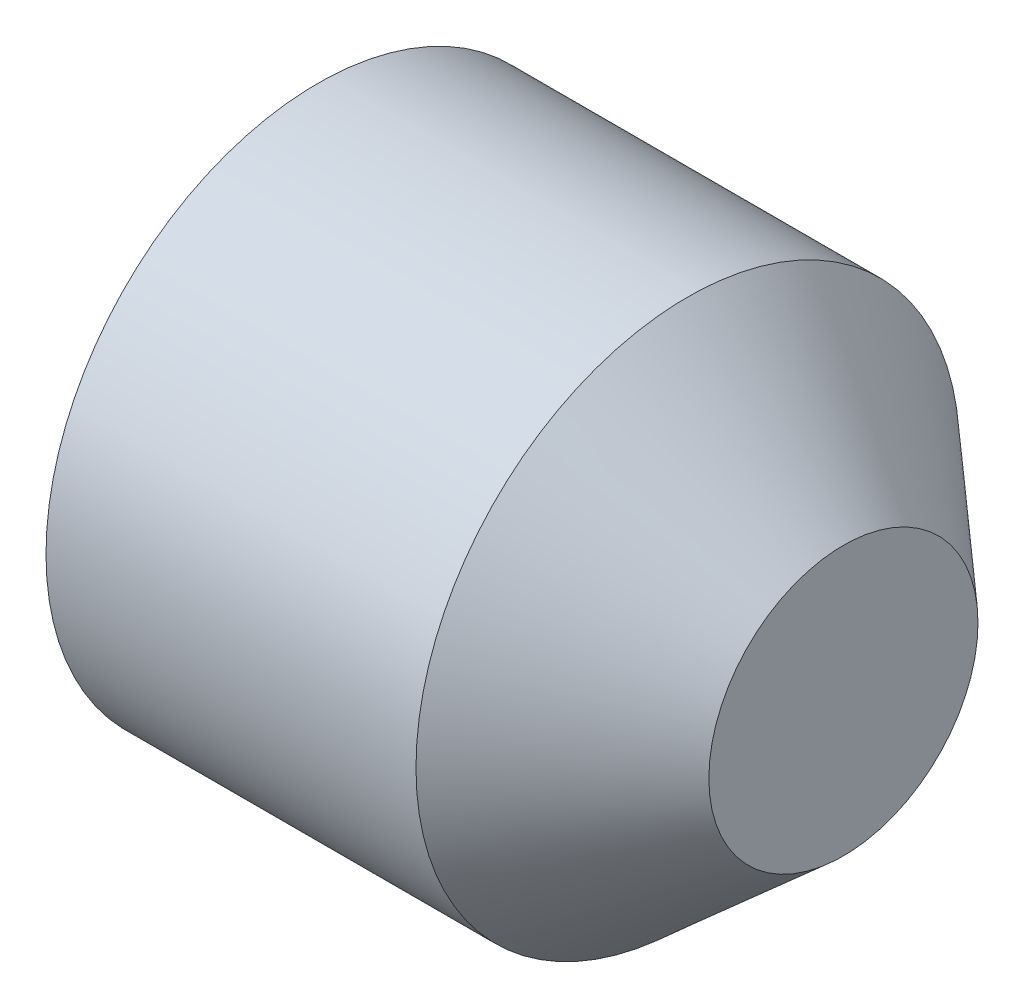
from build123d import *

# Parameters (mm, degrees)
SKETCH9_R           = 1.61
BOSS_EXTRUDE1_DEPTH = 3
CIRPATTERN5_COUNT   = 12
CIRPATTERN6_COUNT   = 12


with BuildPart() as part:
    # Sketch1 → Revolve1 (revolve)
    with BuildSketch(Plane.XY):
        Polygon((0, 50), (67, 50), (67, 150), (271.13431362, 150), (356.984864911, 74.249513566), (356.984864911, 0), (0, 0), align=None)
    revolve(axis=Axis((0, 0, 0), (1, 0, 0)))

    # Sketch3 → Cut-Loft1 section 0
    with BuildSketch(Plane.ZY):
        with BuildLine():
            Line((-1, 24.842486485), (-2.446479865, 52.442966509))
            ThreePointArc((-2.446479865, 52.442966509), (0, 52.5), (2.446479865, 52.442966509))
            Line((2.446479865, 52.442966509), (1, 24.842486485))
            Line((1, 24.842486485), (-1, 24.842486485))
        make_face()
    # Sketch12 → Cut-Loft1 section 1
    with BuildSketch(Plane.ZY.offset(-25)):
        with BuildLine():
            Line((-22.339750272, 46.956741345), (-10.661657412, 22.47311051))
            Line((-10.661657412, 22.47311051), (-8.351958581, 23.429819091))
            Line((-8.351958581, 23.429819091), (-17.40684132, 49.000019135))
            ThreePointArc((-17.40684132, 49.000019135), (-19.899538483, 48.041735691), (-22.339750272, 46.956741345))
        make_face()
    cut_loft1 = loft(mode=Mode.SUBTRACT)

    # CirPattern6: Cut-Loft1 ×12 about axis
    cirpattern6_axis = Axis((0, 0, 0), (1, 0, 0))
    for i in range(1, CIRPATTERN6_COUNT):
        add(cut_loft1.rotate(cirpattern6_axis, i * 360 / CIRPATTERN6_COUNT), mode=Mode.SUBTRACT)


with BuildPart() as body_2:
    # Sketch9 → Boss-Extrude1 (new body)
    with BuildSketch(Plane(origin=(0, 50, 0), x_dir=(1, 0, 0), z_dir=(0, 1, 0))):
        with Locations((35, 0)):
            Circle(SKETCH9_R)
    extrude(amount=BOSS_EXTRUDE1_DEPTH)


with BuildPart() as cirpattern5_1:
    # CirPattern5: pattern copy
    add(body_2.part.rotate(Axis((0, 0, 0), (1, 0, 0)), 1 * 360 / CIRPATTERN5_COUNT))


with BuildPart() as cirpattern5_2:
    # CirPattern5: pattern copy
    add(body_2.part.rotate(Axis((0, 0, 0), (1, 0, 0)), 2 * 360 / CIRPATTERN5_COUNT))


with BuildPart() as cirpattern5_3:
    # CirPattern5: pattern copy
    add(body_2.part.rotate(Axis((0, 0, 0), (1, 0, 0)), 3 * 360 / CIRPATTERN5_COUNT))


with BuildPart() as cirpattern5_4:
    # CirPattern5: pattern copy
    add(body_2.part.rotate(Axis((0, 0, 0), (1, 0, 0)), 4 * 360 / CIRPATTERN5_COUNT))


with BuildPart() as cirpattern5_5:
    # CirPattern5: pattern copy
    add(body_2.part.rotate(Axis((0, 0, 0), (1, 0, 0)), 5 * 360 / CIRPATTERN5_COUNT))


with BuildPart() as cirpattern5_6:
    # CirPattern5: pattern copy
    add(body_2.part.rotate(Axis((0, 0, 0), (1, 0, 0)), 6 * 360 / CIRPATTERN5_COUNT))


with BuildPart() as cirpattern5_7:
    # CirPattern5: pattern copy
    add(body_2.part.rotate(Axis((0, 0, 0), (1, 0, 0)), 7 * 360 / CIRPATTERN5_COUNT))


with BuildPart() as cirpattern5_8:
    # CirPattern5: pattern copy
    add(body_2.part.rotate(Axis((0, 0, 0), (1, 0, 0)), 8 * 360 / CIRPATTERN5_COUNT))


with BuildPart() as cirpattern5_9:
    # CirPattern5: pattern copy
    add(body_2.part.rotate(Axis((0, 0, 0), (1, 0, 0)), 9 * 360 / CIRPATTERN5_COUNT))


with BuildPart() as cirpattern5_10:
    # CirPattern5: pattern copy
    add(body_2.part.rotate(Axis((0, 0, 0), (1, 0, 0)), 10 * 360 / CIRPATTERN5_COUNT))


with BuildPart() as cirpattern5_11:
    # CirPattern5: pattern copy
    add(body_2.part.rotate(Axis((0, 0, 0), (1, 0, 0)), 11 * 360 / CIRPATTERN5_COUNT))


solid = Compound([part.part, body_2.part, cirpattern5_1.part, cirpattern5_2.part, cirpattern5_3.part, cirpattern5_4.part, cirpattern5_5.part, cirpattern5_6.part, cirpattern5_7.part, cirpattern5_8.part, cirpattern5_9.part, cirpattern5_10.part, cirpattern5_11.part])
